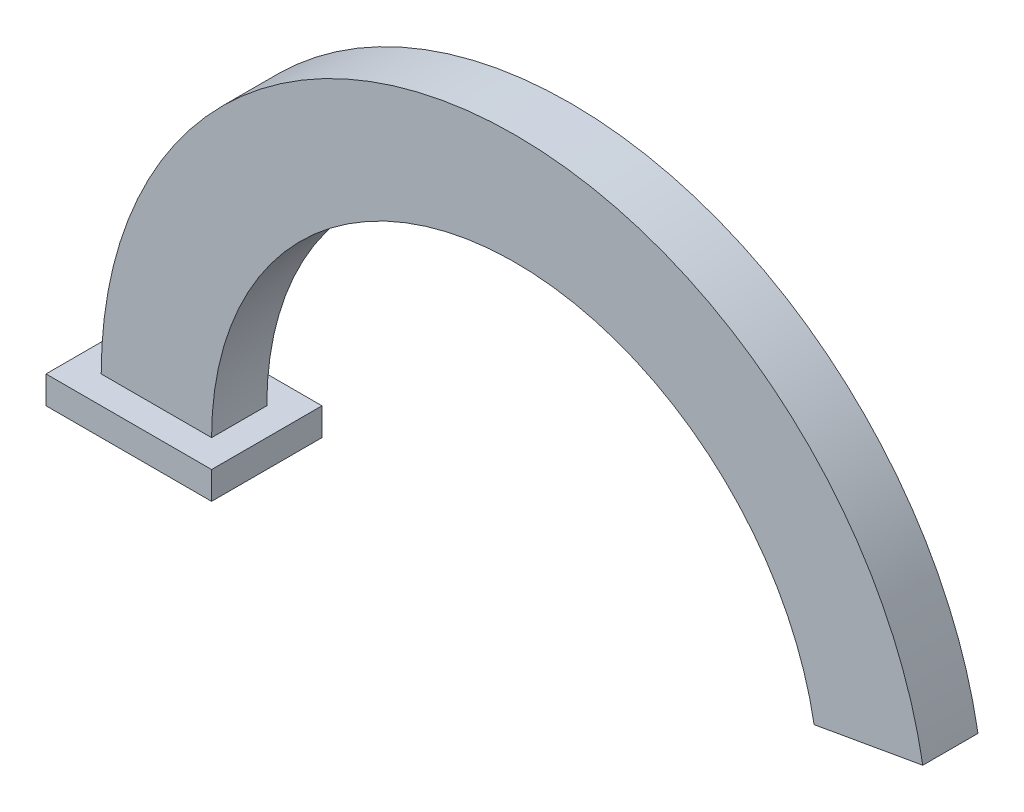
from build123d import *

# Parameters (mm, degrees)
BOSS_EXTRUDE1_DEPTH = 10
SKETCH2_W           = 30
SKETCH2_H           = 20
SKETCH2_W_2         = 20
SKETCH2_H_2         = 10
BOSS_EXTRUDE2_DEPTH = 5


with BuildPart() as part:
    # Sketch1 → Boss-Extrude1 (new body)
    with BuildSketch(Plane.XY):
        with BuildLine():
            Line((-75, 0), (-55, 0))
            ThreePointArc((-55, 0), (-4.793565851, 54.790708395), (54.164426416, 9.550649772))
            Line((54.164426416, 9.550649772), (73.860581476, 13.023613325))
            ThreePointArc((73.860581476, 13.023613325), (-6.536680706, 74.714602357), (-75, 0))
        make_face()
    extrude(amount=BOSS_EXTRUDE1_DEPTH)

    # Sketch2 → Boss-Extrude2 (add)
    with BuildSketch(Plane.XZ):
        with Locations((-65, 5)):
            Rectangle(SKETCH2_W, SKETCH2_H)
        with Locations((-65, 5)):
            Rectangle(SKETCH2_W_2, SKETCH2_H_2, mode=Mode.SUBTRACT)
        Polygon((-65, 5), (-75, 10), (-75, 0), align=None)
        Polygon((-55, 10), (-75, 10), (-65, 5), align=None)
        Polygon((-55, 10), (-65, 5), (-55, 0), align=None)
        Polygon((-55, 0), (-65, 5), (-75, 0), align=None)
    extrude(amount=BOSS_EXTRUDE2_DEPTH)


solid = part.part
